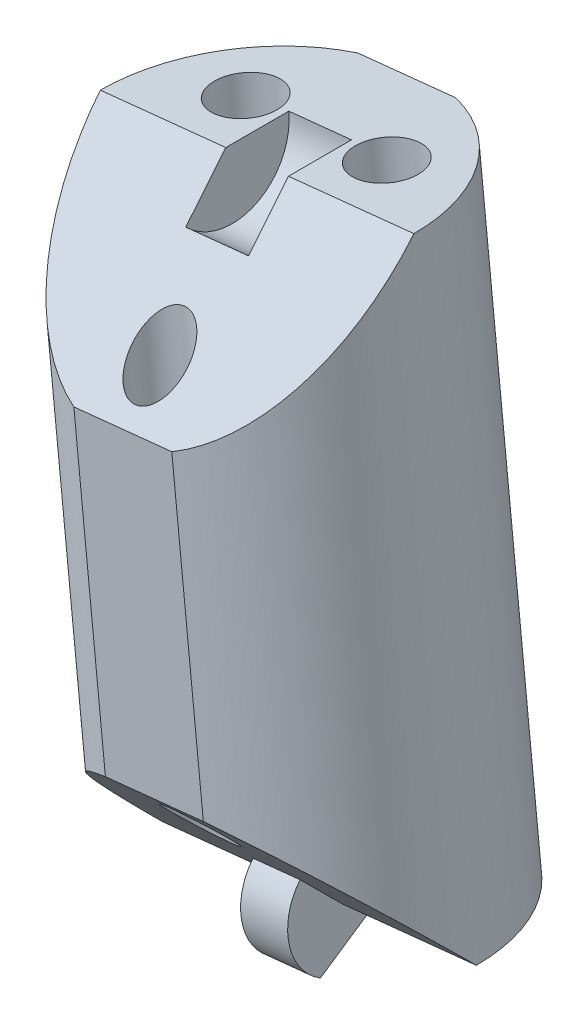
from build123d import *

# Parameters (mm, degrees)
SKETCH3_R               = 8
BOSS_EXTRUDE1_DEPTH     = 30.735789474
CUT_EXTRUDE1_DEPTH      = 12.15350101
CUT_EXTRUDE1_DEPTH_BACK = 12.15350101
BOSS_EXTRUDE2_DEPTH     = 1.2
CUT_EXTRUDE2_DEPTH      = 1.6
SKETCH8_R               = 1.4
SKETCH8_R_2             = 1.6
CUT_EXTRUDE3_DEPTH      = 2.64160469
CUT_EXTRUDE3_DEPTH_BACK = 35.078782599
CUT_EXTRUDE4_DEPTH      = 35.078782599


with BuildPart() as part:
    # Sketch3 → Boss-Extrude1 (new body)
    with BuildSketch(Plane(origin=(-20.344467381, 196.178792599, 0), x_dir=(-0.994665758, -0.103150523, 0), z_dir=(0.103150523, -0.994665758, 0))):
        with Locations((-10.431405186, 0)):
            Circle(SKETCH3_R)
    extrude(amount=BOSS_EXTRUDE1_DEPTH)

    # Sketch4 → Cut-Extrude1 (cut, two sides)
    with BuildSketch(Plane(origin=(10.375761543, 1.076004901, 0), x_dir=(0.103150523, -0.994665758, 0), z_dir=(-0.994665758, -0.103150523, 0))) as cut_extrude1_sk:
        Polygon((-197.230869842, 0), (-189.230869842, 8), (-197.230869842, 8), align=None)
        Polygon((-174.495080368, 8), (-166.495080368, 8), (-166.495080368, 0), align=None)
    extrude(amount=CUT_EXTRUDE1_DEPTH, mode=Mode.SUBTRACT)
    extrude(cut_extrude1_sk.sketch, amount=-CUT_EXTRUDE1_DEPTH_BACK, mode=Mode.SUBTRACT)

    # Sketch5 → Boss-Extrude2 (add, symmetric)
    with BuildSketch(Plane(origin=(10.375761543, 1.076004901, 0), x_dir=(0.103150523, -0.994665758, 0), z_dir=(-0.994665758, -0.103150523, 0))):
        with BuildLine():
            Line((-166.495080368, -2.8), (-164.070209238, 1.4))
            ThreePointArc((-164.070209238, 1.4), (-166.12960703, 2.776045612), (-168.474979356, 1.979898987))
            Line((-168.474979356, 1.979898987), (-166.495080368, 0))
            Line((-166.495080368, 0), (-166.495080368, -2.8))
        make_face()
    extrude(amount=BOSS_EXTRUDE2_DEPTH, both=True)

    # Sketch7 → Cut-Extrude2 (cut, symmetric)
    with BuildSketch(Plane(origin=(10.375761543, 1.076004901, 0), x_dir=(0.103150523, -0.994665758, 0), z_dir=(-0.994665758, -0.103150523, 0))):
        with BuildLine():
            Line((-194.968128142, 2.2627417), (-197.230869842, 0))
            Line((-197.230869842, 0), (-197.230869842, -3.2))
            ThreePointArc((-197.230869842, -3.2), (-194.274455338, -1.224586984), (-194.968128142, 2.2627417))
        make_face()
    extrude(amount=CUT_EXTRUDE2_DEPTH, both=True, mode=Mode.SUBTRACT)

    # Sketch8 → Cut-Extrude3 (cut, two sides)
    with BuildSketch(Plane(origin=(-20.344467381, 196.178792599, 0), x_dir=(0.994665758, 0.103150523, 0), z_dir=(-0.103150523, 0.994665758, 0))) as cut_extrude3_sk:
        with Locations((10.431405186, -5.5)):
            Circle(SKETCH8_R)
        with Locations((6.831405186, 3)):
            Circle(SKETCH8_R_2)
        with Locations((14.031405186, 3)):
            Circle(SKETCH8_R_2)
    extrude(amount=CUT_EXTRUDE3_DEPTH, mode=Mode.SUBTRACT)
    extrude(cut_extrude3_sk.sketch, amount=-CUT_EXTRUDE3_DEPTH_BACK, mode=Mode.SUBTRACT)

    # Sketch9 → Cut-Extrude4 (cut, through all)
    with BuildSketch(Plane(origin=(-20.344467381, 196.178792599, 0), x_dir=(0.994665758, 0.103150523, 0), z_dir=(-0.103150523, 0.994665758, 0))):
        with BuildLine():
            Line((7.933405986, 7.6), (12.929404385, 7.6))
            ThreePointArc((12.929404385, 7.6), (10.431405186, 8), (7.933405986, 7.6))
        make_face()
        with BuildLine():
            Line((7.933405986, -7.6), (12.929404385, -7.6))
            ThreePointArc((12.929404385, -7.6), (10.431405186, -8), (7.933405986, -7.6))
        make_face()
    extrude(amount=-CUT_EXTRUDE4_DEPTH, mode=Mode.SUBTRACT)


solid = part.part
